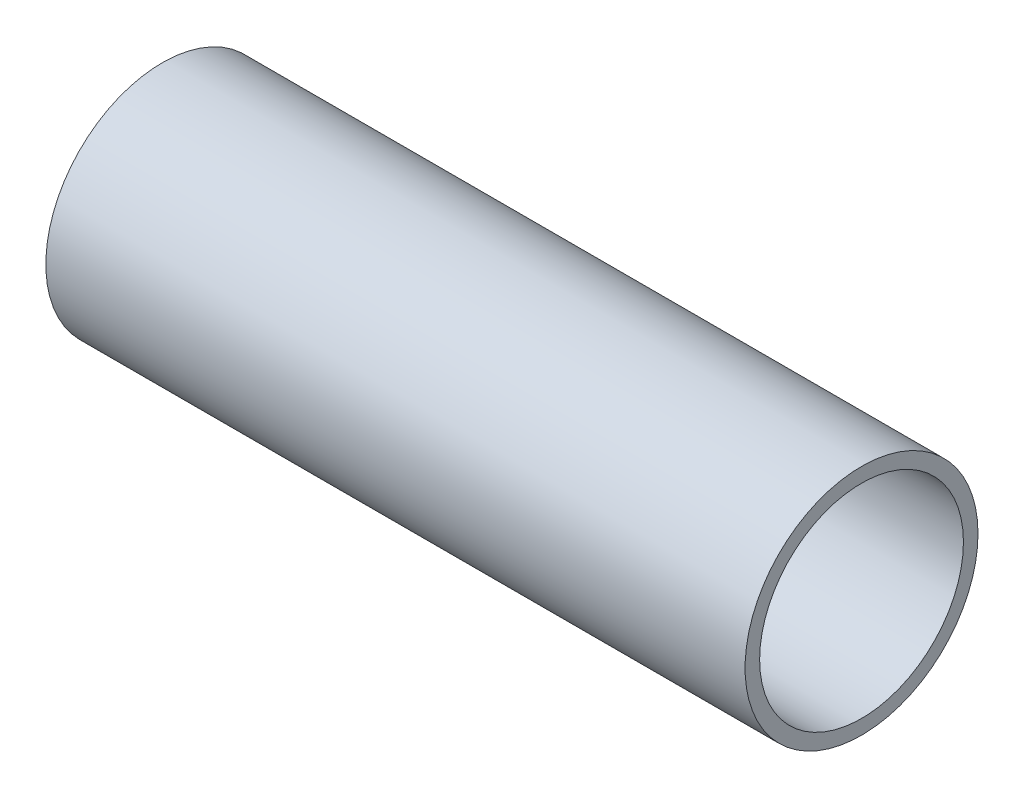
from build123d import *

# Parameters (mm, degrees)
SKETCH1_R           = 50.8
SKETCH1_R_2         = 44.45
BOSS_EXTRUDE1_DEPTH = 305


with BuildPart() as part:
    # Sketch1 → Boss-Extrude1 (new body)
    with BuildSketch(Plane(origin=(0, 0, 0), x_dir=(0, 0, -1), z_dir=(1, 0, 0))):
        Circle(SKETCH1_R)
        Circle(SKETCH1_R_2, mode=Mode.SUBTRACT)
    extrude(amount=BOSS_EXTRUDE1_DEPTH)


solid = part.part
